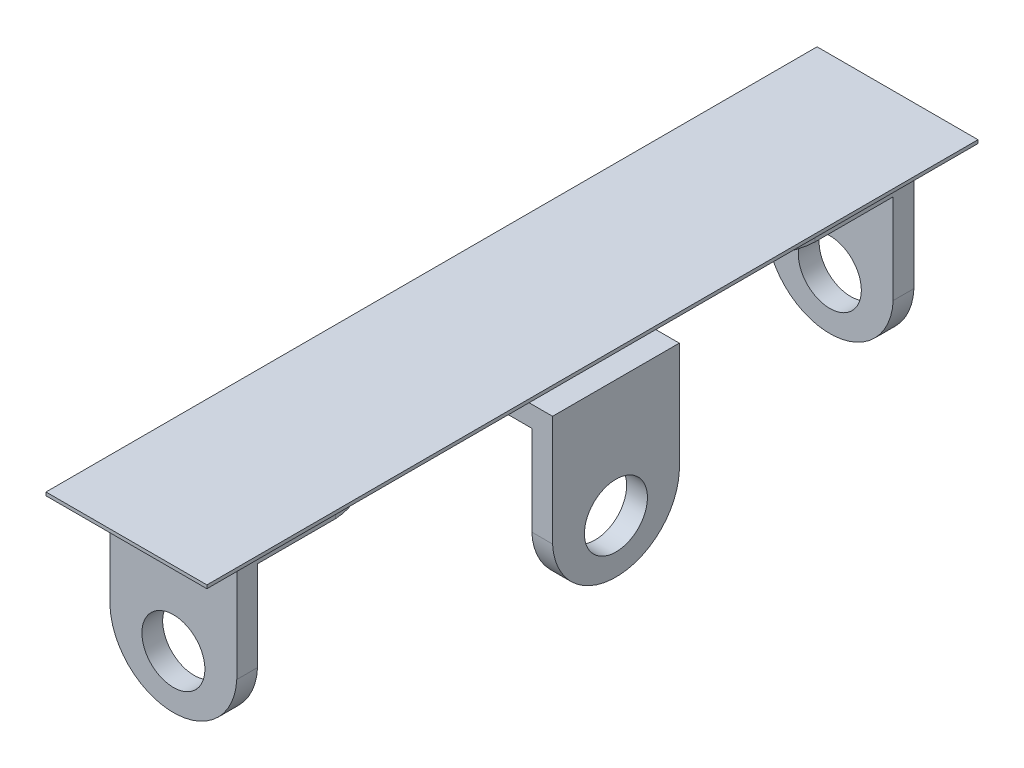
from build123d import *

# Parameters (mm, degrees)
SKETCH1_W           = 6.096
SKETCH1_H           = 29.21
BOSS_EXTRUDE1_DEPTH = 0.127
BOSS_EXTRUDE2_DEPTH = 0.7874
BOSS_EXTRUDE3_DEPTH = 0.7874
BOSS_EXTRUDE4_DEPTH = 0.7874
SKETCH5_R           = 1.1938
BOSS_EXTRUDE5_DEPTH = 0.7874
SKETCH6_R           = 1.1938
BOSS_EXTRUDE6_DEPTH = 0.7874
BOSS_EXTRUDE7_START = 0.7874
SKETCH7_R           = 1.1938
BOSS_EXTRUDE7_DEPTH = 0.7874


with BuildPart() as part:
    # Sketch1 → Boss-Extrude1 (new body)
    with BuildSketch(Plane(origin=(0, 0, 0), x_dir=(1, 0, 0), z_dir=(0, 1, 0))):
        Rectangle(SKETCH1_W, SKETCH1_H)
    extrude(amount=BOSS_EXTRUDE1_DEPTH)

    # Sketch2 → Boss-Extrude2 (add)
    with BuildSketch(Plane(origin=(0, 0, 0), x_dir=(1, 0, 0), z_dir=(0, 1, 0))):
        with BuildLine():
            Line((-0.1171575, -2.4003), (3.5404425, -2.4003))
            Line((3.5404425, -2.4003), (3.5404425, 2.4003))
            Line((3.5404425, 2.4003), (-0.1171575, 2.4003))
            ThreePointArc((-0.1171575, 2.4003), (-2.4031575, 0), (-0.1171575, -2.4003))
        make_face()
    extrude(amount=-BOSS_EXTRUDE2_DEPTH)

    # Sketch3 → Boss-Extrude3 (add)
    with BuildSketch(Plane(origin=(0, 0, 0), x_dir=(1, 0, 0), z_dir=(0, 1, 0))):
        with BuildLine():
            Line((2.4003, 9.0776425), (2.4003, 12.7352425))
            Line((2.4003, 12.7352425), (-2.4003, 12.7352425))
            Line((-2.4003, 12.7352425), (-2.4003, 9.0776425))
            ThreePointArc((-2.4003, 9.0776425), (0, 6.7916425), (2.4003, 9.0776425))
        make_face()
    extrude(amount=-BOSS_EXTRUDE3_DEPTH)

    # Sketch4 → Boss-Extrude4 (add)
    with BuildSketch(Plane(origin=(0, 0, 0), x_dir=(1, 0, 0), z_dir=(0, 1, 0))):
        with BuildLine():
            Line((-2.4003, -12.7352425), (2.4003, -12.7352425))
            Line((2.4003, -12.7352425), (2.4003, -9.0776425))
            ThreePointArc((2.4003, -9.0776425), (0, -6.7916425), (-2.4003, -9.0776425))
            Line((-2.4003, -9.0776425), (-2.4003, -12.7352425))
        make_face()
    extrude(amount=-BOSS_EXTRUDE4_DEPTH)

    # Sketch5 → Boss-Extrude5 (add)
    with BuildSketch(Plane(origin=(3.937, 0, 0), x_dir=(0, 0, -1), z_dir=(1, 0, 0))):
        with BuildLine():
            Line((-2.4003, 0), (-2.4003, -4.191))
            ThreePointArc((-2.4003, -4.191), (0, -6.477), (2.4003, -4.191))
            Line((2.4003, -4.191), (2.4003, 0))
            Line((2.4003, 0), (-2.4003, 0))
        make_face()
        with Locations((0, -4.4577)):
            Circle(SKETCH5_R, mode=Mode.SUBTRACT)
    extrude(amount=-BOSS_EXTRUDE5_DEPTH)

    # Sketch6 → Boss-Extrude6 (add)
    with BuildSketch(Plane.XY.offset(12.827)):
        with BuildLine():
            Line((-2.4003, 0), (-2.4003, -4.191))
            ThreePointArc((-2.4003, -4.191), (0, -6.477), (2.4003, -4.191))
            Line((2.4003, -4.191), (2.4003, 0))
            Line((2.4003, 0), (-2.4003, 0))
        make_face()
        with Locations((0, -4.4577)):
            Circle(SKETCH6_R, mode=Mode.SUBTRACT)
    extrude(amount=-BOSS_EXTRUDE6_DEPTH)

    # Sketch7 → Boss-Extrude7 (add)
    with BuildSketch(Plane.XY.offset(-12.827).offset(BOSS_EXTRUDE7_START)):
        with BuildLine():
            Line((-2.4003, 0), (-2.4003, -4.191))
            ThreePointArc((-2.4003, -4.191), (0, -6.477), (2.4003, -4.191))
            Line((2.4003, -4.191), (2.4003, 0))
            Line((2.4003, 0), (-2.4003, 0))
        make_face()
        with Locations((0, -4.4577)):
            Circle(SKETCH7_R, mode=Mode.SUBTRACT)
    extrude(amount=-BOSS_EXTRUDE7_DEPTH)

    # Sketch8 → Revolve1 (revolve)
    with BuildSketch(Plane.XY):
        with BuildLine():
            Line((0, 0), (1.651, 0))
            Line((1.651, 0), (1.651, -0.7874))
            ThreePointArc((1.651, -0.7874), (0.871501354, -1.202713091), (0, -1.3462))
            Line((0, -1.3462), (0, 0))
        make_face()
    revolve(axis=Axis((0, -1.3462, 0), (0, 1, 0)))

    # Sketch9 → Revolve2 (revolve)
    with BuildSketch(Plane(origin=(0, 0, 0), x_dir=(0, 0, -1), z_dir=(1, 0, 0))):
        with BuildLine():
            Line((9.1948, 0), (10.8458, 0))
            Line((10.8458, 0), (10.8458, -0.7874))
            ThreePointArc((10.8458, -0.7874), (10.066301354, -1.202713091), (9.1948, -1.3462))
            Line((9.1948, -1.3462), (9.1948, 0))
        make_face()
    revolve(axis=Axis((0, -1.3462, -9.1948), (0, 1, 0)))

    # Sketch10 → Revolve3 (revolve)
    with BuildSketch(Plane(origin=(0, 0, 0), x_dir=(0, 0, -1), z_dir=(1, 0, 0))):
        with BuildLine():
            Line((-9.1948, 0), (-7.5438, 0))
            Line((-7.5438, 0), (-7.5438, -0.7874))
            ThreePointArc((-7.5438, -0.7874), (-8.323298646, -1.202713091), (-9.1948, -1.3462))
            Line((-9.1948, -1.3462), (-9.1948, 0))
        make_face()
    revolve(axis=Axis((0, -1.3462, 9.1948), (0, 1, 0)))


solid = part.part
